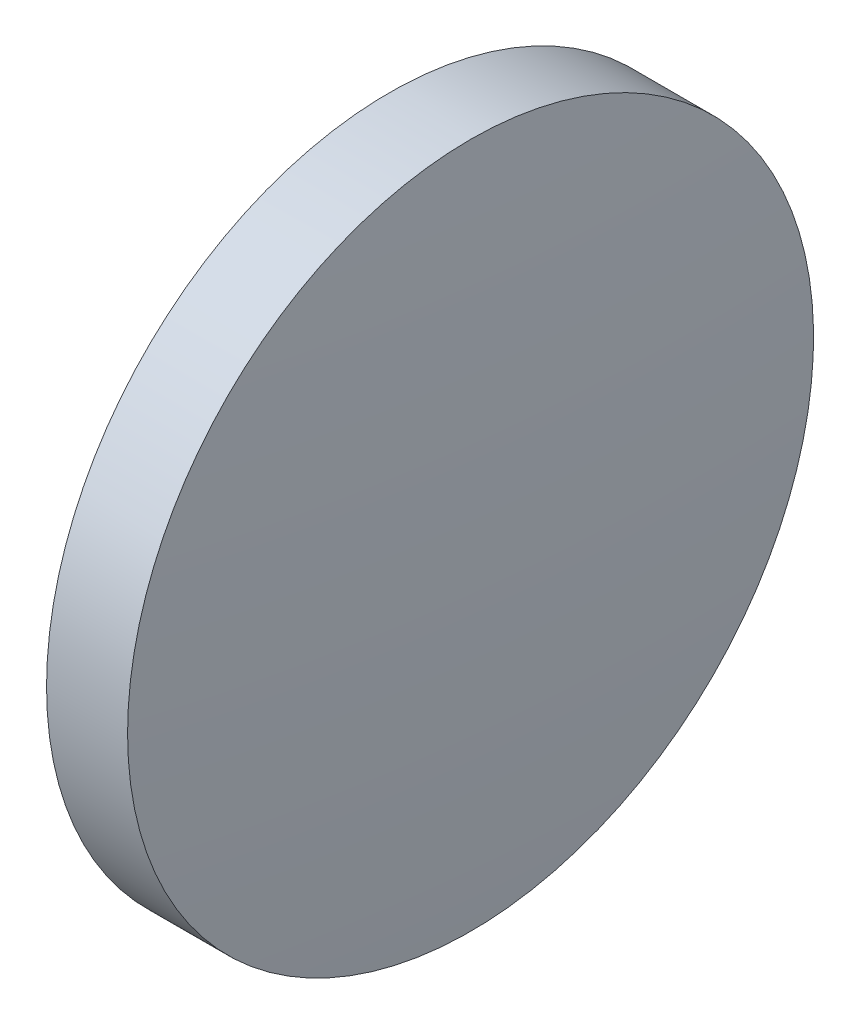
from build123d import *


with BuildPart() as part:
    # 草图1 → 旋转1 (revolve)
    with BuildSketch(Plane.XY):
        with BuildLine():
            Line((115.773606431, 65.233554926), (115.773606431, 77.933554926))
            Line((115.773606431, 77.933554926), (118.773869233, 77.933554926))
            ThreePointArc((118.773869233, 77.933554926), (119.102889426, 71.587342976), (119.212606431, 65.233554926))
            Line((119.212606431, 65.233554926), (115.773606431, 65.233554926))
        make_face()
    revolve(axis=Axis((110.165373228, 65.233554926, 0), (1, 0, 0)))


solid = part.part
